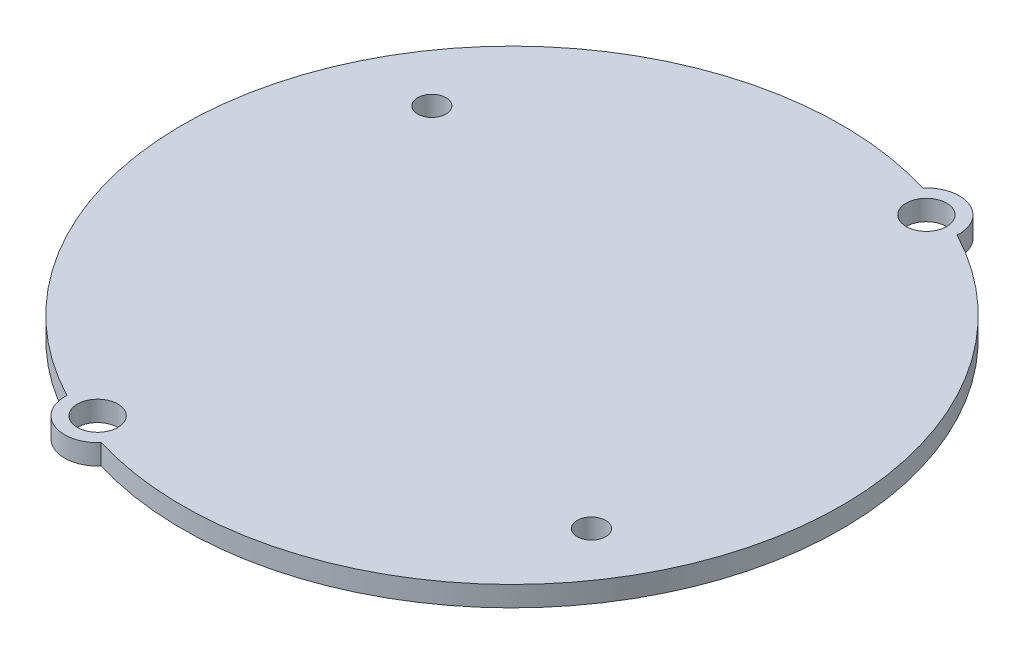
from build123d import *

# Parameters (mm, degrees)
SKETCH1_R           = 2
BOSS_EXTRUDE1_DEPTH = 2
SKETCH6_R           = 1.4
CUT_EXTRUDE1_DEPTH  = 10


with BuildPart() as part:
    # Sketch1 → Boss-Extrude1 (new body)
    with BuildSketch(Plane(origin=(0, 0, 0), x_dir=(1, 0, 0), z_dir=(0, 1, 0))):
        with BuildLine():
            ThreePointArc((9.383115236, 31.116027196), (-30.08527478, 12.293341344), (-15.092629238, -28.783025253))
            ThreePointArc((-15.092629238, -28.783025253), (-13.079214236, -32.008527478), (-9.383115236, -31.116027196))
            ThreePointArc((-9.383115236, -31.116027196), (30.08527478, -12.293341344), (15.092629238, 28.783025253))
            ThreePointArc((15.092629238, 28.783025253), (13.079214236, 32.008527478), (9.383115236, 31.116027196))
        make_face()
        with Locations((11.849880102, 29)):
            Circle(SKETCH1_R, mode=Mode.SUBTRACT)
        with Locations((-11.849880102, -29)):
            Circle(SKETCH1_R, mode=Mode.SUBTRACT)
    extrude(amount=BOSS_EXTRUDE1_DEPTH)

    # Sketch6 → Cut-Extrude1 (cut)
    with BuildSketch(Plane.XZ):
        with Locations((-21.83, -13.926611625)):
            Circle(SKETCH6_R)
        with Locations((22.12, 14.29)):
            Circle(SKETCH6_R)
    extrude(amount=-CUT_EXTRUDE1_DEPTH, mode=Mode.SUBTRACT)


solid = part.part
